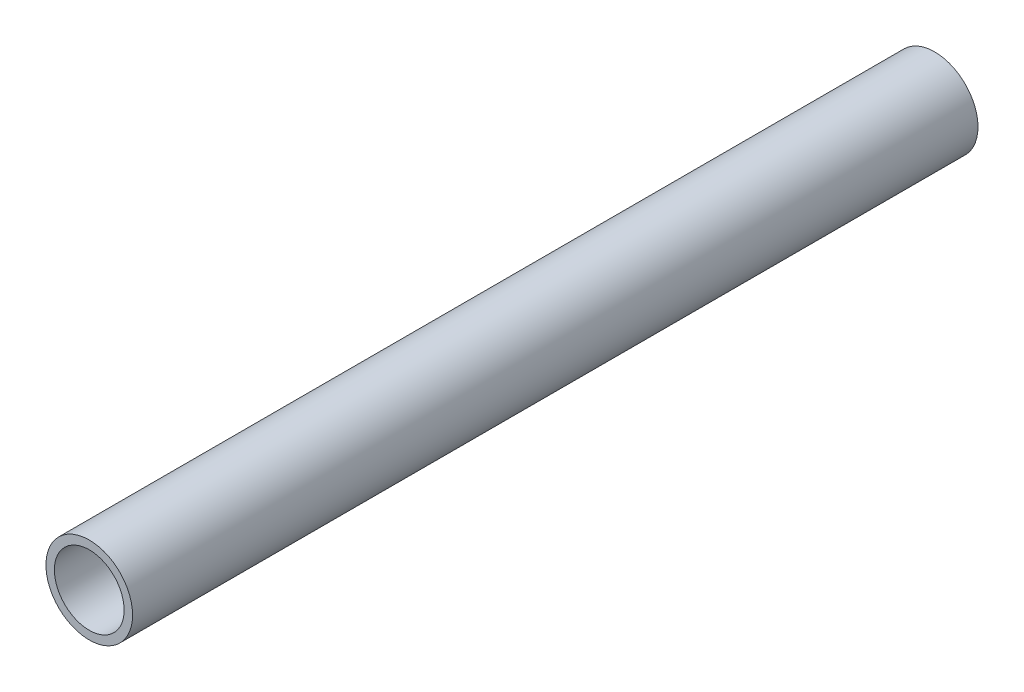
from build123d import *

# Parameters (mm, degrees)
SKETCH1_R           = 10.25
SKETCH1_R_2         = 8.25
BOSS_EXTRUDE1_DEPTH = 200


with BuildPart() as part:
    # Sketch1 → Boss-Extrude1 (new body)
    with BuildSketch(Plane.XY):
        Circle(SKETCH1_R)
        Circle(SKETCH1_R_2, mode=Mode.SUBTRACT)
    extrude(amount=BOSS_EXTRUDE1_DEPTH)


solid = part.part
